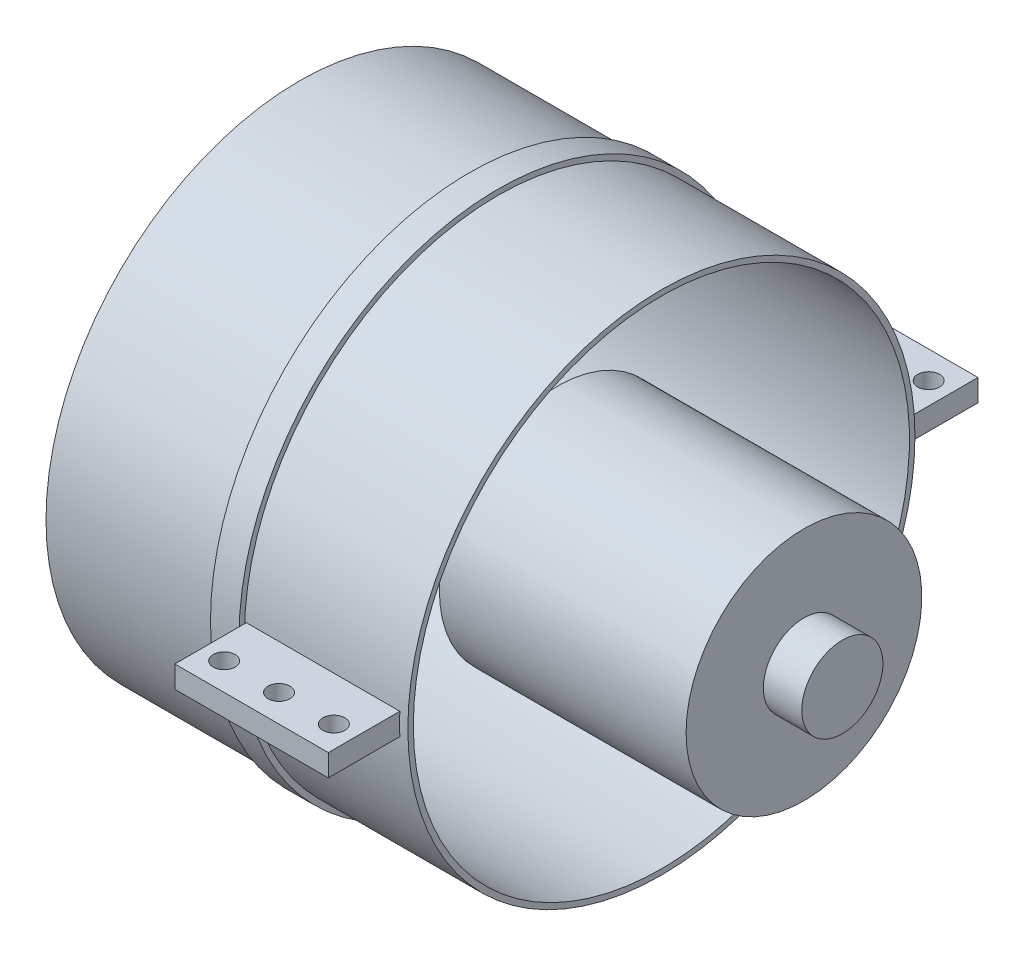
from build123d import *

# Parameters (mm, degrees)
BOSS_EXTRUDE1_START = -1.5
BOSS_EXTRUDE1_DEPTH = 28
SKETCH3_R           = 2
CUT_EXTRUDE1_DEPTH  = 126.447698265
CIRPATTERN1_COUNT   = 2


with BuildPart() as part:
    # Sketch1 → Revolve1 (revolve)
    with BuildSketch(Plane(origin=(0, 0, 0), x_dir=(1, 0, 0), z_dir=(0, 1, 0))):
        Polygon((0, 45.25), (0, 46.25), (31, 46.25), (31, 47.25), (36.2, 47.25), (36.2, 46.25), (66, 46.25), (66, 45.25), align=None)
        Polygon((47, 21.5), (92, 21.5), (92, 7.4), (99, 7.4), (99, 0), (47, 0), align=None)
    revolve(axis=Axis((0, 0, 0), (1, 0, 0)))

    # Sketch2 → Boss-Extrude1 (add)
    with BuildSketch(Plane(origin=(66, 0, 0), x_dir=(0, 0, -1), z_dir=(1, 0, 0)).offset(BOSS_EXTRUDE1_START)):
        with BuildLine():
            Line((46.206736522, -2), (59.25, -2))
            Line((59.25, -2), (59.25, 2))
            Line((59.25, 2), (46.206736522, 2))
            ThreePointArc((46.206736522, 2), (46.25, 0), (46.206736522, -2))
        make_face()
    boss_extrude1 = extrude(amount=-BOSS_EXTRUDE1_DEPTH)

    # Sketch3 → Cut-Extrude1 (cut, through all)
    with BuildSketch(Plane(origin=(0, 2, 0), x_dir=(1, 0, 0), z_dir=(0, 1, 0))):
        with Locations((60.5, 54.25)):
            Circle(SKETCH3_R)
        with Locations((50.5, 54.25)):
            Circle(SKETCH3_R)
        with Locations((40.5, 54.25)):
            Circle(SKETCH3_R)
    cut_extrude1 = extrude(amount=-CUT_EXTRUDE1_DEPTH, mode=Mode.SUBTRACT)

    # CirPattern1: Boss-Extrude1, Cut-Extrude1 ×2 about axis
    cirpattern1_axis = Axis((173.098931414, 0, 0), (-1, 0, 0))
    add([boss_extrude1.rotate(cirpattern1_axis, i * 360 / CIRPATTERN1_COUNT) for i in range(1, CIRPATTERN1_COUNT)])
    add([cut_extrude1.rotate(cirpattern1_axis, i * 360 / CIRPATTERN1_COUNT) for i in range(1, CIRPATTERN1_COUNT)], mode=Mode.SUBTRACT)


solid = part.part
